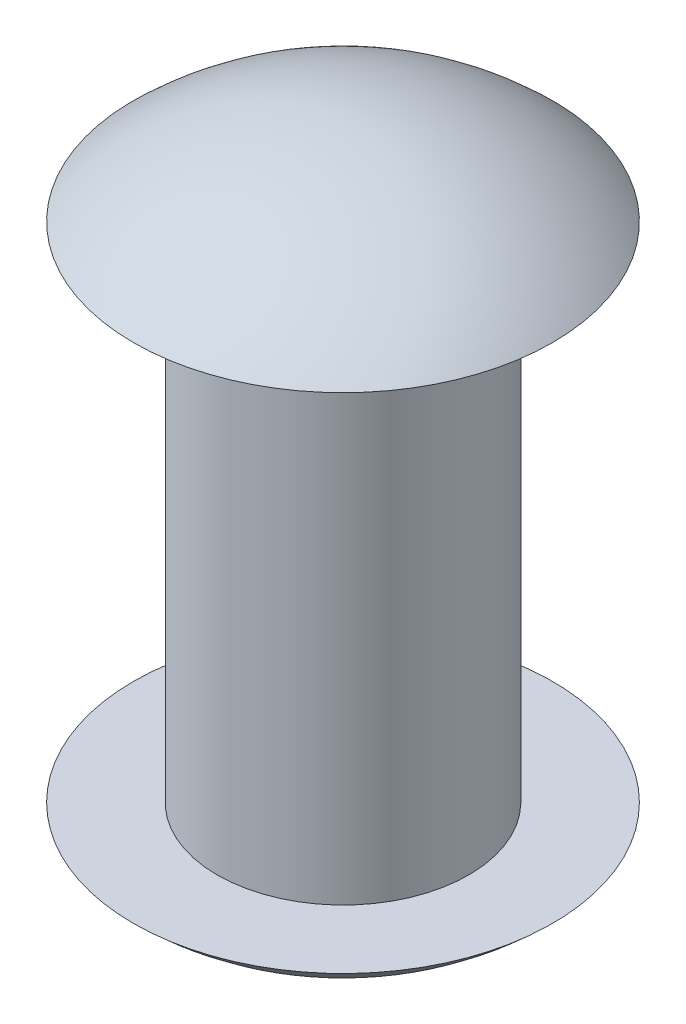
from build123d import *


with BuildPart() as part:
    # Эскиз1 → Повернуть1 (revolve)
    with BuildSketch(Plane.XY):
        with BuildLine():
            Line((15, -30), (15, 30))
            Line((15, 30), (25, 30))
            ThreePointArc((25, 30), (13.462912018, 37.407280045), (0, 40))
            Line((0, 40), (0, -40))
            ThreePointArc((0, -40), (13.462912018, -37.407280045), (25, -30))
            Line((25, -30), (15, -30))
        make_face()
    revolve(axis=Axis((0, 79.672131148, 0), (0, -1, 0)))


solid = part.part
